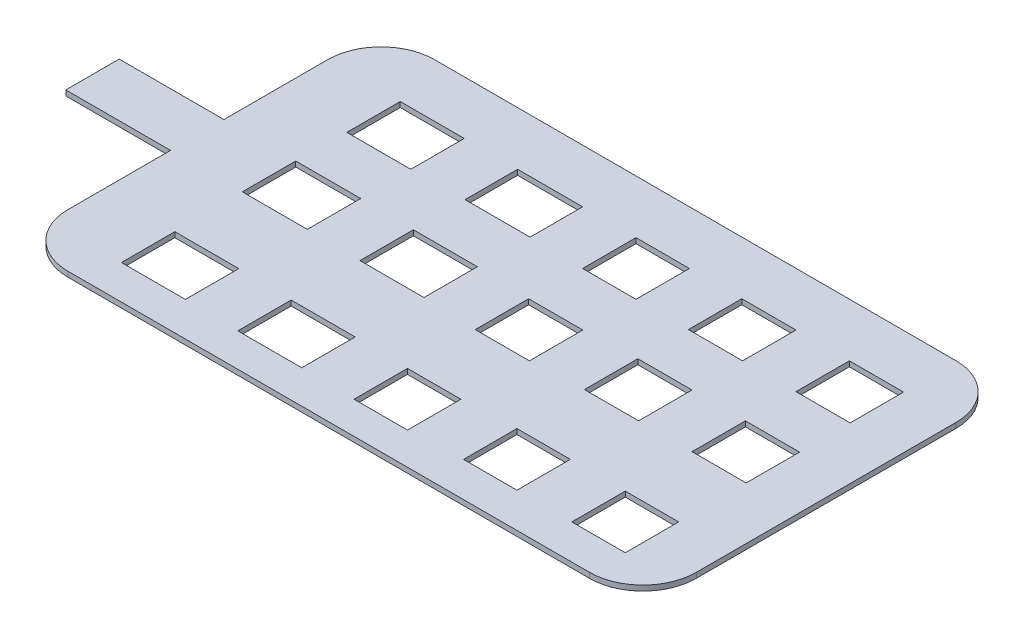
from build123d import *

# Parameters (mm, degrees)
SKETCH5_W           = 0.517150716
SKETCH5_H           = 0.51
SKETCH5_W_2         = 0.610833794
SKETCH5_W_3         = 0.62059831
SKETCH5_H_2         = 0.501976926
SKETCH5_W_4         = 0.610833795
SKETCH5_W_5         = 0.51
SKETCH5_W_6         = 0.517150715
BOSS_EXTRUDE1_DEPTH = 0.05


with BuildPart() as part:
    # Sketch5 → Boss-Extrude1 (new body)
    with BuildSketch(Plane(origin=(0, 0, 0), x_dir=(1, 0, 0), z_dir=(0, 1, 0))):
        with BuildLine():
            Line((-2.46823367, -1.737302974), (2.51176633, -1.737302974))
            ThreePointArc((2.51176633, -1.737302974), (2.872390788, -1.587927433), (3.02176633, -1.227302974))
            Line((3.02176633, -1.227302974), (3.02176633, 1.252697026))
            ThreePointArc((3.02176633, 1.252697026), (2.872390788, 1.613321484), (2.51176633, 1.762697026))
            Line((2.51176633, 1.762697026), (-2.46823367, 1.762697026))
            ThreePointArc((-2.46823367, 1.762697026), (-2.828858129, 1.613321484), (-2.97823367, 1.252697026))
            Line((-2.97823367, 1.252697026), (-2.97823367, 0.261786557))
            Line((-2.97823367, 0.261786557), (-3.97823367, 0.261786557))
            Line((-3.97823367, 0.261786557), (-3.97823367, -0.248213443))
            Line((-3.97823367, -0.248213443), (-2.97823367, -0.248213443))
            Line((-2.97823367, -0.248213443), (-2.97823367, -1.227302974))
            ThreePointArc((-2.97823367, -1.227302974), (-2.828858129, -1.587927433), (-2.46823367, -1.737302974))
        make_face()
        with Locations((0.217439849, -0.020233416)):
            Rectangle(SKETCH5_W, SKETCH5_H, mode=Mode.SUBTRACT)
        with Locations((-1.98, 0.997697026)):
            Rectangle(SKETCH5_W_2, SKETCH5_H, mode=Mode.SUBTRACT)
        with Locations((-1.98, -1.155)):
            Rectangle(SKETCH5_W_2, SKETCH5_H, mode=Mode.SUBTRACT)
        with Locations((-1.982268458, 0.006786557)):
            Rectangle(SKETCH5_W_3, SKETCH5_H, mode=Mode.SUBTRACT)
        with Locations((-0.856552406, -0.000270924)):
            Rectangle(SKETCH5_W_2, SKETCH5_H, mode=Mode.SUBTRACT)
        with Locations((-0.854283948, 1.001708563)):
            Rectangle(SKETCH5_W_3, SKETCH5_H_2, mode=Mode.SUBTRACT)
        with Locations((-0.859166206, -1.164640938)):
            Rectangle(SKETCH5_W_4, SKETCH5_H, mode=Mode.SUBTRACT)
        with Locations((0.221015207, 0.997697026)):
            Rectangle(SKETCH5_W_5, SKETCH5_H, mode=Mode.SUBTRACT)
        with Locations((0.211250692, -1.174838915)):
            Rectangle(SKETCH5_W_5, SKETCH5_H, mode=Mode.SUBTRACT)
        with Locations((2.265552123, -1.149528229)):
            Rectangle(SKETCH5_W_5, SKETCH5_H, mode=Mode.SUBTRACT)
        with Locations((1.23482605, 0.00507727)):
            Rectangle(SKETCH5_W_6, SKETCH5_H, mode=Mode.SUBTRACT)
        with Locations((1.23482605, 0.997697026)):
            Rectangle(SKETCH5_W_6, SKETCH5_H, mode=Mode.SUBTRACT)
        with Locations((1.231250692, -1.149528229)):
            Rectangle(SKETCH5_W_5, SKETCH5_H, mode=Mode.SUBTRACT)
        with Locations((2.261976765, 0.00507727)):
            Rectangle(SKETCH5_W, SKETCH5_H, mode=Mode.SUBTRACT)
        with Locations((2.261976765, 0.997697026)):
            Rectangle(SKETCH5_W, SKETCH5_H, mode=Mode.SUBTRACT)
    extrude(amount=BOSS_EXTRUDE1_DEPTH)


solid = part.part
